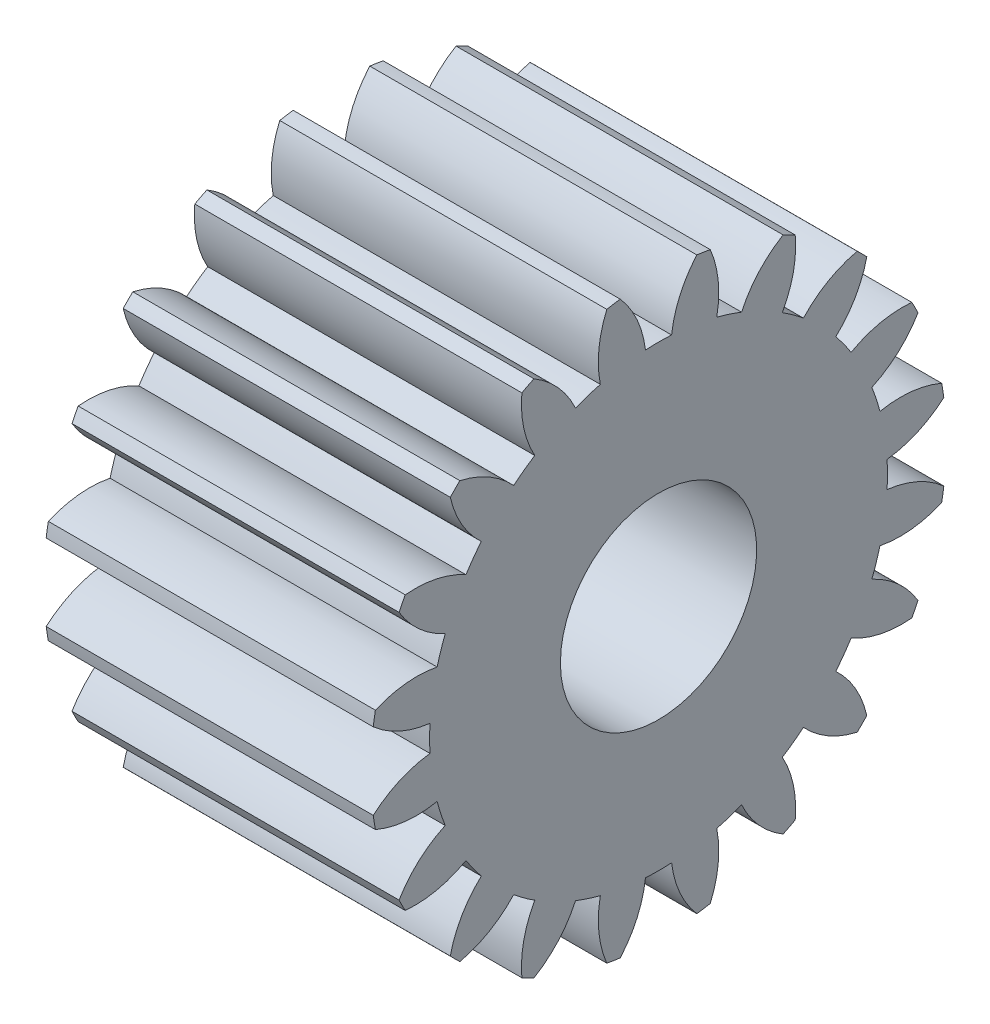
from build123d import *

# Parameters (mm, degrees)
BASPROSKE_W     = 10
BASPROSKE_H     = 8.8
TOOTHCUT_DEPTH  = 16.964961635
TEETHCUTS_COUNT = 20
TEETHCUTS_ANGLE = 342
BORSKE_R        = 3
BORE_DEPTH      = 50.0000508


with BuildPart() as part:
    # BasProSke → Base-Revolve (revolve)
    with BuildSketch(Plane(origin=(0, 0, 0), x_dir=(1, 0, 0), z_dir=(0, 1, 0)), mode=Mode.PRIVATE) as base_revolve_sk:
        with Locations((5, 4.4)):
            Rectangle(BASPROSKE_W, BASPROSKE_H)
    revolve(base_revolve_sk.sketch.rotate(Axis((-10, 0, 0), (1, 0, 0)), 180), axis=Axis((-10, 0, 0), (1, 0, 0)))

    # TooCutSke → ToothCut (cut, through all)
    with BuildSketch(Plane(origin=(0, 0, 0), x_dir=(0, 0, -1), z_dir=(1, 0, 0))):
        with BuildLine():
            ThreePointArc((0.39930266, 6.987600331), (0, 6.999), (-0.39930266, 6.987600331))
            ThreePointArc((-0.39930266, 6.987600331), (-0.659963343, 7.927158116), (-1.191466546, 8.744603629))
            ThreePointArc((-1.191466546, 8.744603629), (0, 8.8254), (1.191466546, 8.744603629))
            ThreePointArc((1.191466546, 8.744603629), (0.659963343, 7.927158116), (0.39930266, 6.987600331))
        make_face()
    toothcut = extrude(amount=TOOTHCUT_DEPTH, mode=Mode.SUBTRACT)

    # TeethCuts: ToothCut ×20 about axis
    teethcuts_axis = Axis((-10, 0, 0), (1, 0, 0))
    for i in range(1, TEETHCUTS_COUNT):
        add(toothcut.rotate(teethcuts_axis, i * TEETHCUTS_ANGLE / (TEETHCUTS_COUNT - 1)), mode=Mode.SUBTRACT)

    # BorSke → Bore (cut, symmetric)
    with BuildSketch(Plane(origin=(0, 0, 0), x_dir=(0, 0, -1), z_dir=(1, 0, 0))):
        with Locations(Location((0, 0, 0), (0, 0, 180))):
            Circle(BORSKE_R)
    extrude(amount=BORE_DEPTH, both=True, mode=Mode.SUBTRACT)


solid = part.part
